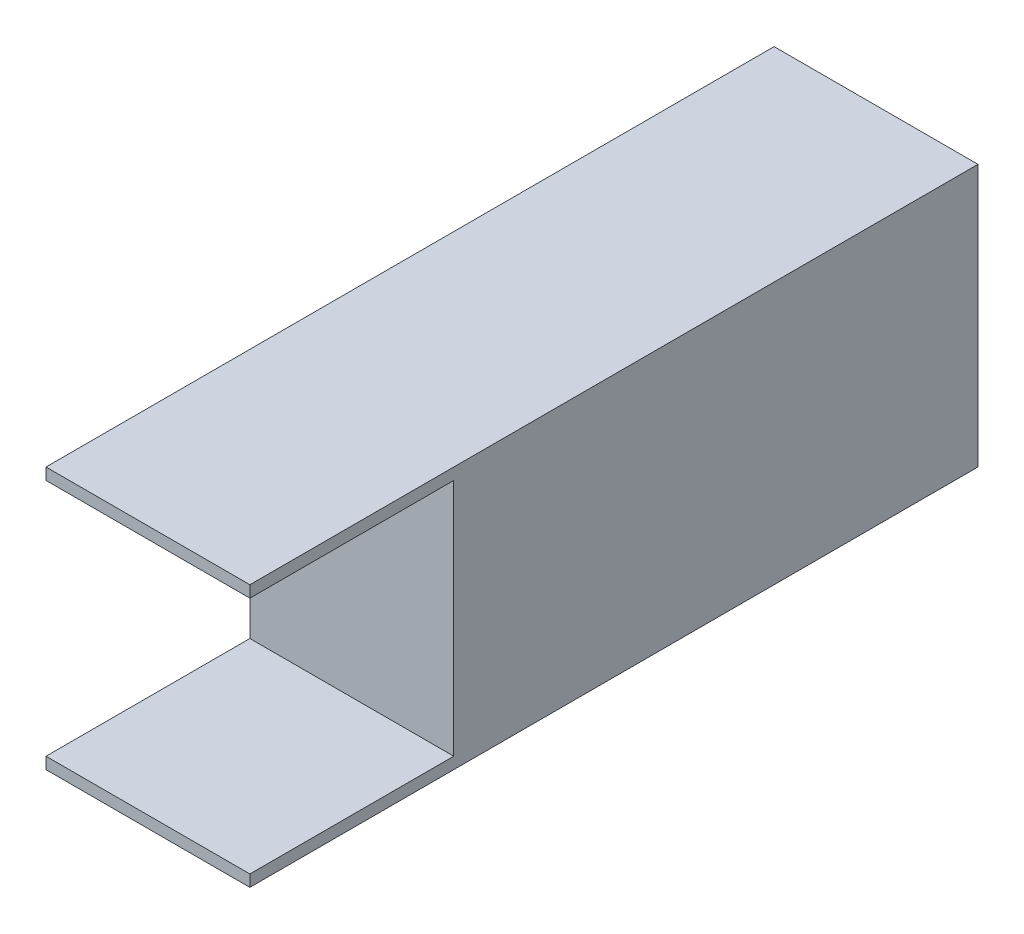
from build123d import *

# Parameters (mm, degrees)
SKETCH1_W           = 35
SKETCH1_H           = 45
BOSS_EXTRUDE1_DEPTH = 125
SKETCH2_W           = 35
SKETCH2_H           = 41
CUT_EXTRUDE1_DEPTH  = 36


with BuildPart() as part:
    # Sketch1 → Boss-Extrude1 (new body)
    with BuildSketch(Plane.XY):
        Rectangle(SKETCH1_W, SKETCH1_H)
    extrude(amount=BOSS_EXTRUDE1_DEPTH)

    # Sketch2 → Cut-Extrude1 (cut, through all)
    with BuildSketch(Plane.ZY.offset(17.5)):
        with Locations((107.5, 0)):
            Rectangle(SKETCH2_W, SKETCH2_H)
    extrude(amount=-CUT_EXTRUDE1_DEPTH, mode=Mode.SUBTRACT)


solid = part.part
